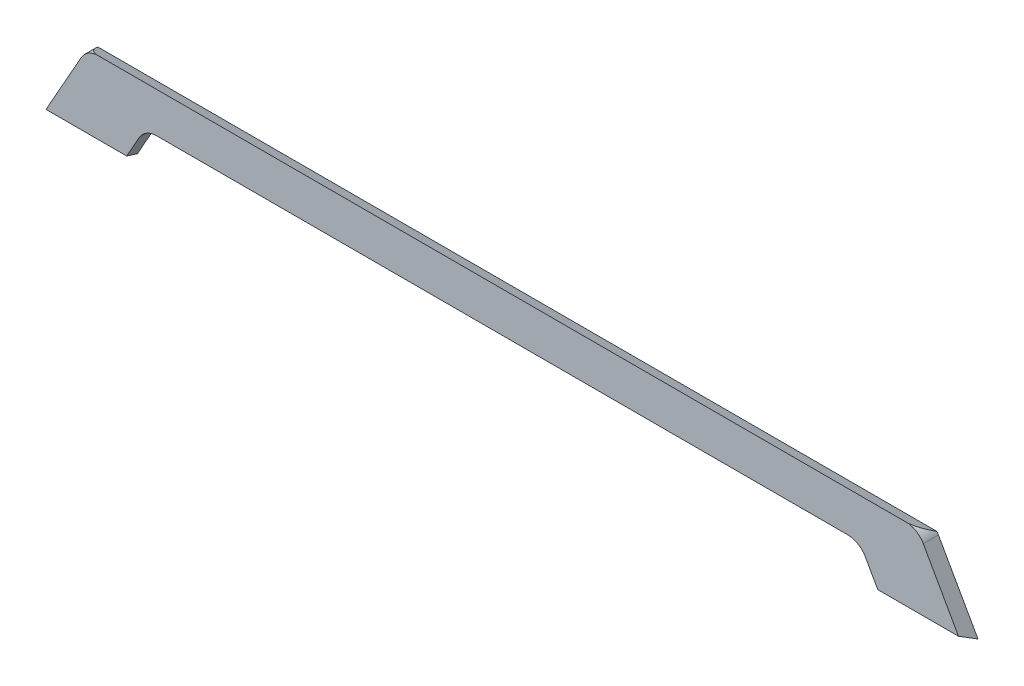
from build123d import *

# Parameters (mm, degrees)
BOSS_EXTRUDE1_DEPTH     = 19.05
SKETCH2_W               = 197.138384739
SKETCH2_H               = 233.965884384
CUT_EXTRUDE1_DEPTH      = 580.97531403
CUT_EXTRUDE1_DEPTH_BACK = 580.97531403


with BuildPart() as part:
    # Sketch1 → Boss-Extrude1 (new body)
    with BuildSketch(Plane.XY):
        with BuildLine():
            Line((508, 0), (-508, 0))
            ThreePointArc((-508, 0), (-520.8192309, -3.472224939), (-530.133638711, -12.93958117))
            Line((-530.133638711, -12.93958117), (-579.97531403, -101.474136014))
            Line((-579.97531403, -101.474136014), (-478.37531403, -101.474136014))
            Line((-478.37531403, -101.474136014), (-457.132157229, -63.73958117))
            ThreePointArc((-457.132157229, -63.73958117), (-447.817749418, -54.272224939), (-434.998518519, -50.8))
            Line((-434.998518519, -50.8), (434.998518519, -50.8))
            ThreePointArc((434.998518519, -50.8), (447.817749418, -54.272224939), (457.132157229, -63.73958117))
            Line((457.132157229, -63.73958117), (478.37531403, -101.474136014))
            Line((478.37531403, -101.474136014), (579.97531403, -101.474136014))
            Line((579.97531403, -101.474136014), (530.133638711, -12.93958117))
            ThreePointArc((530.133638711, -12.93958117), (520.8192309, -3.472224939), (508, 0))
        make_face()
    extrude(amount=BOSS_EXTRUDE1_DEPTH)

    # Sketch2 → Cut-Extrude1 (cut, two sides)
    with BuildSketch(Plane(origin=(0, 0, 0), x_dir=(0, 0, -1), z_dir=(1, 0, 0))) as cut_extrude1_sk:
        with Locations((-13.729414766, -53.345438188)):
            Rectangle(SKETCH2_W, SKETCH2_H)
        Polygon((0, -101.474136014), (-60.85250598, -70.206121999), (-23.664545619, 2.167536884), (37.187960361, -29.100477131), align=None, mode=Mode.SUBTRACT)
    extrude(amount=CUT_EXTRUDE1_DEPTH, mode=Mode.SUBTRACT)
    extrude(cut_extrude1_sk.sketch, amount=-CUT_EXTRUDE1_DEPTH_BACK, mode=Mode.SUBTRACT)


solid = part.part
